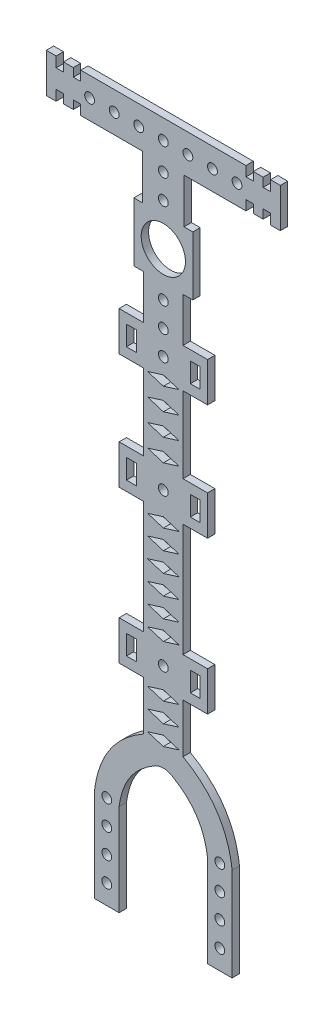
from build123d import *

# Parameters (mm, degrees)
SKETCH_1_R      = 4.5
SKETCH_1_R_2    = 1
SKETCH_1_W      = 2
SKETCH_1_H      = 4
EXTRUDE_1_DEPTH = 1.5


with BuildPart() as part:
    # 草图1 → 凸台-拉伸1 (new body)
    with BuildSketch(Plane.XY):
        with BuildLine():
            Line((6, 7), (4.211145618, 7))
            Line((4.211145618, 7), (4.211145618, 16.105572809))
            Line((4.211145618, 16.105572809), (16.816086672, 16.105572809))
            Line((16.816086672, 16.105572809), (16.816086672, 18.105572809))
            Line((16.816086672, 18.105572809), (18.316086672, 18.105572809))
            Line((18.316086672, 18.105572809), (18.316086672, 16.405572809))
            Line((18.316086672, 16.405572809), (20.316086672, 16.405572809))
            Line((20.316086672, 16.405572809), (20.316086672, 18.211145609))
            Line((20.316086672, 18.211145609), (21.816086672, 18.211145609))
            Line((21.816086672, 18.211145609), (21.816086672, 16.105572809))
            Line((21.816086672, 16.105572809), (23.816086672, 16.105572809))
            Line((23.816086672, 16.105572809), (23.816086672, 24.1055728))
            Line((23.816086672, 24.1055728), (21.816086672, 24.1055728))
            Line((21.816086672, 24.1055728), (21.816086672, 22))
            Line((21.816086672, 22), (20.316086672, 22))
            Line((20.316086672, 22), (20.316086672, 23.8055728))
            Line((20.316086672, 23.8055728), (18.316086672, 23.8055728))
            Line((18.316086672, 23.8055728), (18.316086672, 22.1055728))
            Line((18.316086672, 22.1055728), (16.816086672, 22.1055728))
            Line((16.816086672, 22.1055728), (16.816086672, 24.1055728))
            Line((16.816086672, 24.1055728), (-16.816086672, 24.1055728))
            Line((-16.816086672, 24.1055728), (-16.816086672, 22.1055728))
            Line((-16.816086672, 22.1055728), (-18.316086672, 22.1055728))
            Line((-18.316086672, 22.1055728), (-18.316086672, 23.8055728))
            Line((-18.316086672, 23.8055728), (-20.316086672, 23.8055728))
            Line((-20.316086672, 23.8055728), (-20.316086672, 22))
            Line((-20.316086672, 22), (-21.816086672, 22))
            Line((-21.816086672, 22), (-21.816086672, 24.1055728))
            Line((-21.816086672, 24.1055728), (-23.816086672, 24.1055728))
            Line((-23.816086672, 24.1055728), (-23.816086672, 16.105572809))
            Line((-23.816086672, 16.105572809), (-21.816086672, 16.105572809))
            Line((-21.816086672, 16.105572809), (-21.816086672, 18.211145609))
            Line((-21.816086672, 18.211145609), (-20.316086672, 18.211145609))
            Line((-20.316086672, 18.211145609), (-20.316086672, 16.405572809))
            Line((-20.316086672, 16.405572809), (-18.316086672, 16.405572809))
            Line((-18.316086672, 16.405572809), (-18.316086672, 18.105572809))
            Line((-18.316086672, 18.105572809), (-16.816086672, 18.105572809))
            Line((-16.816086672, 18.105572809), (-16.816086672, 16.105572809))
            Line((-16.816086672, 16.105572809), (-4.211145618, 16.105572809))
            Line((-4.211145618, 16.105572809), (-4.211145618, 7))
            Line((-4.211145618, 7), (-6, 7))
            Line((-6, 7), (-6, -5))
            Line((-6, -5), (-4, -5))
            Line((-4, -5), (-4, -14))
            Line((-4, -14), (-9, -14))
            Line((-9, -14), (-9, -22))
            Line((-9, -22), (-4, -22))
            Line((-4, -22), (-4, -37.5))
            Line((-4, -37.5), (-9, -37.5))
            Line((-9, -37.5), (-9, -45.5))
            Line((-9, -45.5), (-4, -45.5))
            Line((-4, -45.5), (-4, -68.5))
            Line((-4, -68.5), (-9, -68.5))
            Line((-9, -68.5), (-9, -76.5))
            Line((-9, -76.5), (-4, -76.5))
            Line((-4, -76.5), (-4, -86.5))
            add(Edge.make_bspline(
                [(-4, -86.5), (-12.824800186, -91.446472906), (-14, -101.5)],
                knots=[0, 0, 0, 1, 1, 1], degree=2))
            Line((-14, -101.5), (-14, -120.5))
            Line((-14, -120.5), (-9, -120.5))
            Line((-9, -120.5), (-9, -101.807652325))
            add(Edge.make_bspline(
                [(-1.555258324, -90.861563726), (-4.124118351, -92.324075576), (-6.772437427, -95.35168045), (-8.60156745, -98.914074006), (-9, -101.807652325)],
                knots=[0, 0, 0, 0.368595186, 0.61432531, 0.982920497, 0.982920497, 0.982920497], degree=2))
            add(Edge.make_bspline(
                [(-1.555258324, -90.861563726), (0, -90.152312688), (1.555258324, -90.861563726)],
                knots=[0, 0, 0, 1, 1, 1], degree=2))
            add(Edge.make_bspline(
                [(1.555258324, -90.861563726), (4.124118351, -92.324075576), (6.772437427, -95.35168045), (8.60156745, -98.914074006), (9, -101.807652325)],
                knots=[0, 0, 0, 0.368595186, 0.61432531, 0.982920497, 0.982920497, 0.982920497], degree=2))
            Line((9, -101.807652325), (9, -120.5))
            Line((9, -120.5), (14, -120.5))
            Line((14, -120.5), (14, -101.5))
            add(Edge.make_bspline(
                [(4, -86.5), (12.824800186, -91.446472906), (14, -101.5)],
                knots=[0, 0, 0, 1, 1, 1], degree=2))
            Line((4, -86.5), (4, -76.5))
            Line((4, -76.5), (9, -76.5))
            Line((9, -76.5), (9, -68.5))
            Line((9, -68.5), (4, -68.5))
            Line((4, -68.5), (4, -45.5))
            Line((4, -45.5), (9, -45.5))
            Line((9, -45.5), (9, -37.5))
            Line((9, -37.5), (4, -37.5))
            Line((4, -37.5), (4, -22))
            Line((4, -22), (9, -22))
            Line((9, -22), (9, -14))
            Line((9, -14), (4, -14))
            Line((4, -14), (4, -5))
            Line((4, -5), (6, -5))
            Line((6, -5), (6, 7))
        make_face()
        with Locations((0, 1)):
            Circle(SKETCH_1_R, mode=Mode.SUBTRACT)
        with Locations((15, 20.105572805)):
            Circle(SKETCH_1_R_2, mode=Mode.SUBTRACT)
        with Locations((-15, 20.105572805)):
            Circle(SKETCH_1_R_2, mode=Mode.SUBTRACT)
        with Locations((-10, 20.105572805)):
            Circle(SKETCH_1_R_2, mode=Mode.SUBTRACT)
        with Locations((0, 14.54049212)):
            Circle(SKETCH_1_R_2, mode=Mode.SUBTRACT)
        with Locations((-5, 20.105572805)):
            Circle(SKETCH_1_R_2, mode=Mode.SUBTRACT)
        with Locations((0, 9.54049212)):
            Circle(SKETCH_1_R_2, mode=Mode.SUBTRACT)
        with Locations((0, 20.105572805)):
            Circle(SKETCH_1_R_2, mode=Mode.SUBTRACT)
        with Locations((5, 20.105572805)):
            Circle(SKETCH_1_R_2, mode=Mode.SUBTRACT)
        with Locations((10, 20.105572805)):
            Circle(SKETCH_1_R_2, mode=Mode.SUBTRACT)
        with Locations((6.5, -18)):
            Rectangle(SKETCH_1_W, SKETCH_1_H, mode=Mode.SUBTRACT)
        with Locations((-11.5, -116.5)):
            Circle(SKETCH_1_R_2, mode=Mode.SUBTRACT)
        with Locations((-11.5, -111.5)):
            Circle(SKETCH_1_R_2, mode=Mode.SUBTRACT)
        with Locations((-11.5, -106.5)):
            Circle(SKETCH_1_R_2, mode=Mode.SUBTRACT)
        with Locations((-11.5, -101.5)):
            Circle(SKETCH_1_R_2, mode=Mode.SUBTRACT)
        with Locations((-6.5, -72.5)):
            Rectangle(SKETCH_1_W, SKETCH_1_H, mode=Mode.SUBTRACT)
        with Locations((11.5, -116.5)):
            Circle(SKETCH_1_R_2, mode=Mode.SUBTRACT)
        with Locations((11.5, -111.5)):
            Circle(SKETCH_1_R_2, mode=Mode.SUBTRACT)
        with Locations((11.5, -106.5)):
            Circle(SKETCH_1_R_2, mode=Mode.SUBTRACT)
        Polygon((-3.2, -85.7), (0, -84.7), (3.2, -85.7), (0, -86.7), align=None, mode=Mode.SUBTRACT)
        with Locations((11.5, -101.5)):
            Circle(SKETCH_1_R_2, mode=Mode.SUBTRACT)
        Polygon((-3.2, -81.7), (0, -80.7), (3.2, -81.7), (0, -82.7), align=None, mode=Mode.SUBTRACT)
        Polygon((-3.2, -77.7), (0, -76.7), (3.2, -77.7), (0, -78.7), align=None, mode=Mode.SUBTRACT)
        with Locations((0, -72.5)):
            Circle(SKETCH_1_R_2, mode=Mode.SUBTRACT)
        Polygon((-3.2, -67.2), (0, -66.2), (3.2, -67.2), (0, -68.2), align=None, mode=Mode.SUBTRACT)
        with Locations((6.5, -72.5)):
            Rectangle(SKETCH_1_W, SKETCH_1_H, mode=Mode.SUBTRACT)
        Polygon((-3.2, -63.2), (0, -62.2), (3.2, -63.2), (0, -64.2), align=None, mode=Mode.SUBTRACT)
        Polygon((-3.2, -59.2), (0, -58.2), (3.2, -59.2), (0, -60.2), align=None, mode=Mode.SUBTRACT)
        Polygon((-3.2, -55.2), (0, -54.2), (3.2, -55.2), (0, -56.2), align=None, mode=Mode.SUBTRACT)
        Polygon((-3.2, -51.2), (0, -50.2), (3.2, -51.2), (0, -52.2), align=None, mode=Mode.SUBTRACT)
        with Locations((-6.5, -41.5)):
            Rectangle(SKETCH_1_W, SKETCH_1_H, mode=Mode.SUBTRACT)
        Polygon((-3.2, -35.7), (0, -34.7), (3.2, -35.7), (0, -36.7), align=None, mode=Mode.SUBTRACT)
        Polygon((-3.2, -31.2), (0, -30.2), (3.2, -31.2), (0, -32.2), align=None, mode=Mode.SUBTRACT)
        with Locations((-6.5, -18)):
            Rectangle(SKETCH_1_W, SKETCH_1_H, mode=Mode.SUBTRACT)
        Polygon((-3.2, -26.7), (0, -25.7), (3.2, -26.7), (0, -27.7), align=None, mode=Mode.SUBTRACT)
        Polygon((-3.2, -22.2), (0, -21.2), (3.2, -22.2), (0, -23.2), align=None, mode=Mode.SUBTRACT)
        with Locations((0, -13)):
            Circle(SKETCH_1_R_2, mode=Mode.SUBTRACT)
        with Locations((0, -8)):
            Circle(SKETCH_1_R_2, mode=Mode.SUBTRACT)
        Polygon((-3.2, -47.2), (0, -46.2), (3.2, -47.2), (0, -48.2), align=None, mode=Mode.SUBTRACT)
        with Locations((0, -41.5)):
            Circle(SKETCH_1_R_2, mode=Mode.SUBTRACT)
        with Locations((6.5, -41.5)):
            Rectangle(SKETCH_1_W, SKETCH_1_H, mode=Mode.SUBTRACT)
        with Locations((0, -18)):
            Circle(SKETCH_1_R_2, mode=Mode.SUBTRACT)
    extrude(amount=EXTRUDE_1_DEPTH)


solid = part.part
